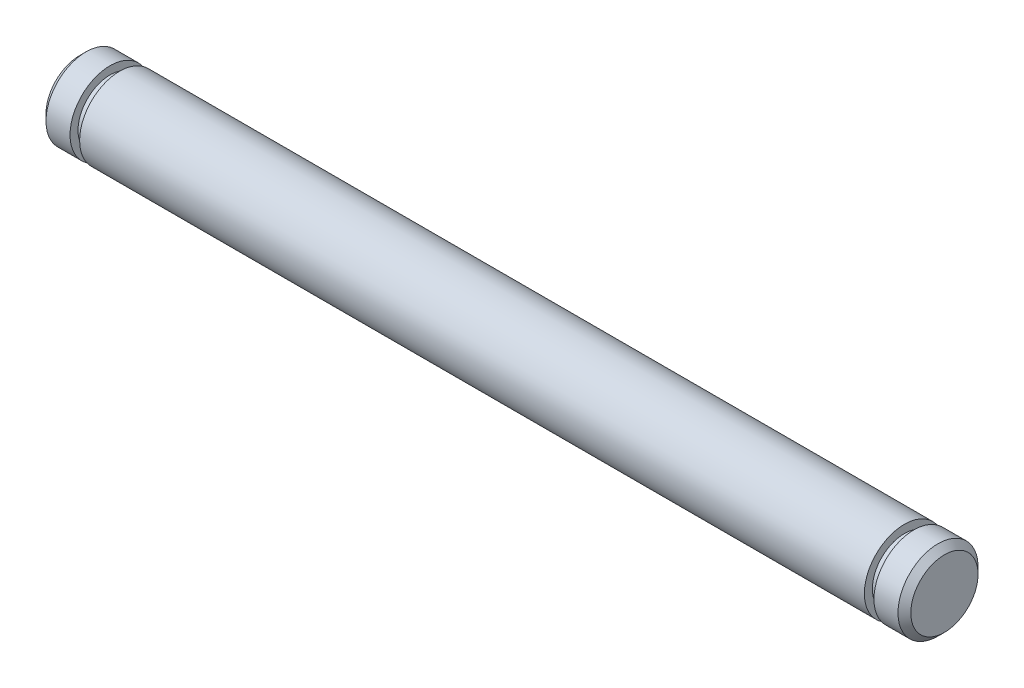
from build123d import *


with BuildPart() as part:
    # Sketch1 → Revolve1 (revolve)
    with BuildSketch(Plane.XY):
        Polygon((0.6, 2.5), (49.6, 2.5), (49.6, 2), (50.2, 2), (50.2, 2.5), (51.7, 2.5), (52.1, 2.1), (52.1, 0), (-1.9, 0), (-1.9, 2.1), (-1.5, 2.5), (0, 2.5), (0, 2), (0.6, 2), align=None)
    revolve(axis=Axis((-4.6, 0, 0), (1, 0, 0)))


solid = part.part
